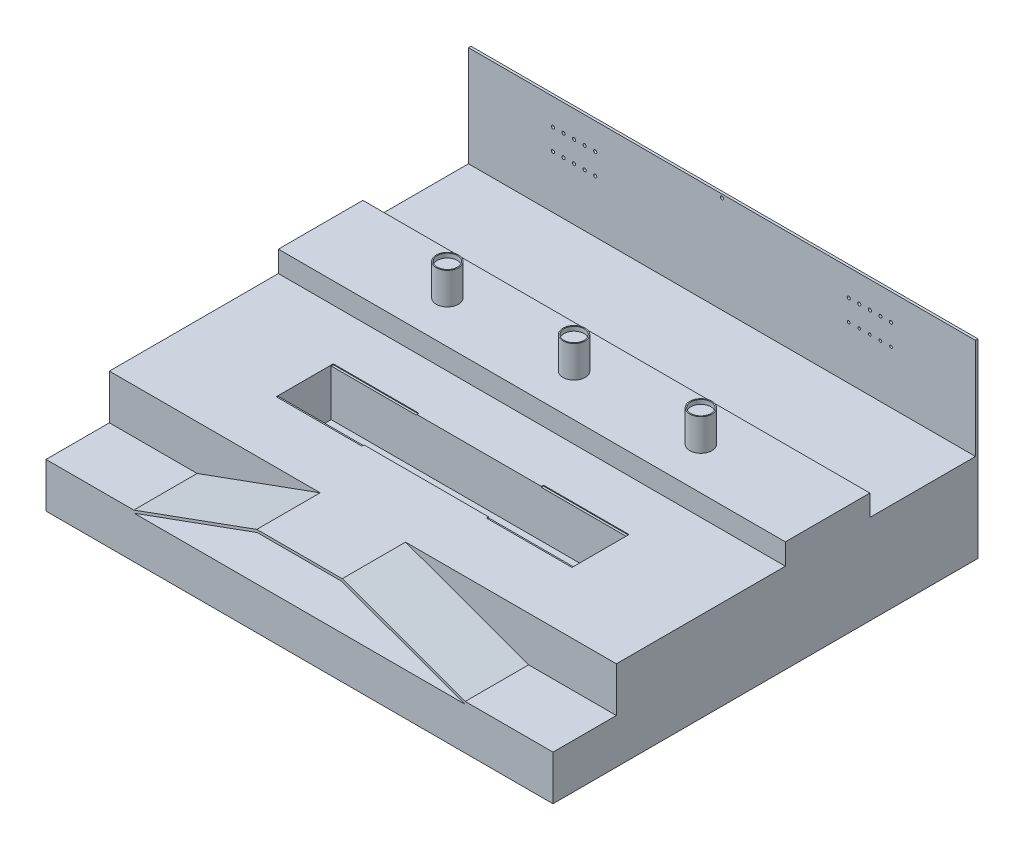
from build123d import *

# Parameters (mm, degrees)
EXTRUDE_1_DEPTH     = 300
SKETCH_2_W          = 2400
SKETCH_2_H          = 224
EXTRUDE_2_DEPTH     = 800
SKETCH_4_W          = 1400
SKETCH_4_H          = 250
CUT_EXTRUDE_1_DEPTH = 225
SKETCH_7_W          = 2400
SKETCH_7_H          = 324
EXTRUDE_3_DEPTH     = 400
SKETCH_9_W          = 2400
SKETCH_9_H          = 224
EXTRUDE_5_DEPTH     = 500
SKETCH_10_W         = 2400
SKETCH_10_H         = 700
EXTRUDE_6_DEPTH     = 12
SKETCH_12_W         = 2400
SKETCH_12_H         = 2012
EXTRUDE_8_DEPTH     = 200
SKETCH_13_R         = 52.5
EXTRUDE_9_DEPTH     = 150
SKETCH_14_R         = 7.5
SKETCH_14_R_2       = 6.5
CUT_EXTRUDE_2_DEPTH = 13
SKETCH_16_R         = 47.5
CUT_EXTRUDE_3_DEPTH = 20
SKETCH_17_W         = 405
SKETCH_17_H         = 10
CUT_EXTRUDE_4_DEPTH = 4


with BuildPart() as part:
    # 草图1 → 凸台-拉伸1 (new body)
    with BuildSketch(Plane.XY):
        Polygon((-200, 0), (200, 0), (782.465212924, -212), (1200, -212), (1200, -200), (784.581136693, -200), (202.115923769, 12), (-202.115923769, 12), (-784.581136693, -200), (-1200, -200), (-1200, -212), (-782.465212924, -212), align=None)
    extrude(amount=EXTRUDE_1_DEPTH)

    # 草图2 → 凸台-拉伸2 (add)
    with BuildSketch(Plane(origin=(0, 0, 0), x_dir=(-1, 0, 0), z_dir=(0, 0, -1))):
        with Locations((0, -100)):
            Rectangle(SKETCH_2_W, SKETCH_2_H)
    extrude(amount=EXTRUDE_2_DEPTH)

    # 草图4 → 切除-拉伸1 (cut, through all)
    with BuildSketch(Plane(origin=(0, 12, 0), x_dir=(1, 0, 0), z_dir=(0, 1, 0))):
        with Locations((0, 425)):
            Rectangle(SKETCH_4_W, SKETCH_4_H)
    extrude(amount=-CUT_EXTRUDE_1_DEPTH, mode=Mode.SUBTRACT)

    # 草图7 → 凸台-拉伸3 (add)
    with BuildSketch(Plane(origin=(0, 0, -800), x_dir=(-1, 0, 0), z_dir=(0, 0, -1))):
        with Locations((0, -50)):
            Rectangle(SKETCH_7_W, SKETCH_7_H)
    extrude(amount=EXTRUDE_3_DEPTH)

    # 草图9 → 凸台-拉伸5 (add)
    with BuildSketch(Plane(origin=(0, 0, -1200), x_dir=(-1, 0, 0), z_dir=(0, 0, -1))):
        with Locations((0, -100)):
            Rectangle(SKETCH_9_W, SKETCH_9_H)
    extrude(amount=EXTRUDE_5_DEPTH)

    # 草图10 → 凸台-拉伸6 (add)
    with BuildSketch(Plane(origin=(0, 0, -1700), x_dir=(-1, 0, 0), z_dir=(0, 0, -1))):
        with Locations((0, 138)):
            Rectangle(SKETCH_10_W, SKETCH_10_H)
    extrude(amount=EXTRUDE_6_DEPTH)

    # 草图12 → 凸台-拉伸8 (add)
    with BuildSketch(Plane.XZ.offset(212)):
        with Locations((0, -706)):
            Rectangle(SKETCH_12_W, SKETCH_12_H)
    extrude(amount=EXTRUDE_8_DEPTH)

    # 草图13 → 凸台-拉伸9 (add)
    with BuildSketch(Plane(origin=(0, 112, 0), x_dir=(1, 0, 0), z_dir=(0, 1, 0))):
        with Locations((-600, 1000)):
            Circle(SKETCH_13_R)
        with Locations((600, 1000)):
            Circle(SKETCH_13_R)
        with Locations((0, 1000)):
            Circle(SKETCH_13_R)
    extrude(amount=EXTRUDE_9_DEPTH)

    # 草图14 → 切除-拉伸2 (cut, through all)
    with BuildSketch(Plane.XY.offset(-1700)):
        with Locations((-800, 262)):
            Circle(SKETCH_14_R)
        with Locations((800, 362)):
            Circle(SKETCH_14_R)
        with Locations((-750, 262)):
            Circle(SKETCH_14_R)
        with Locations((-700, 262)):
            Circle(SKETCH_14_R)
        with Locations((-650, 262)):
            Circle(SKETCH_14_R)
        with Locations((-600, 262)):
            Circle(SKETCH_14_R)
        with Locations((750, 362)):
            Circle(SKETCH_14_R)
        with Locations((700, 362)):
            Circle(SKETCH_14_R)
        with Locations((650, 362)):
            Circle(SKETCH_14_R)
        with Locations((600, 362)):
            Circle(SKETCH_14_R)
        with Locations((0, 472)):
            Circle(SKETCH_14_R)
        with Locations((-800, 362)):
            Circle(SKETCH_14_R)
        with Locations((-750, 362)):
            Circle(SKETCH_14_R)
        with Locations((-700, 362)):
            Circle(SKETCH_14_R)
        with Locations((-650, 362)):
            Circle(SKETCH_14_R)
        with Locations((-600, 362)):
            Circle(SKETCH_14_R)
        with Locations((800, 262)):
            Circle(SKETCH_14_R_2)
        with Locations((750, 262)):
            Circle(SKETCH_14_R_2)
        with Locations((700, 262)):
            Circle(SKETCH_14_R_2)
        with Locations((650, 262)):
            Circle(SKETCH_14_R_2)
        with Locations((600, 262)):
            Circle(SKETCH_14_R_2)
    extrude(amount=-CUT_EXTRUDE_2_DEPTH, mode=Mode.SUBTRACT)

    # 草图16 → 切除-拉伸3 (cut)
    with BuildSketch(Plane(origin=(0, 262, 0), x_dir=(1, 0, 0), z_dir=(0, 1, 0))):
        with Locations((-600, 1000)):
            Circle(SKETCH_16_R)
        with Locations((0, 1000)):
            Circle(SKETCH_16_R)
        with Locations((600, 1000)):
            Circle(SKETCH_16_R)
    extrude(amount=-CUT_EXTRUDE_3_DEPTH, mode=Mode.SUBTRACT)

    # 草图17 → 切除-拉伸4 (cut)
    with BuildSketch(Plane(origin=(0, 12, 0), x_dir=(1, 0, 0), z_dir=(0, 1, 0))):
        with Locations((-497.5, 555)):
            Rectangle(SKETCH_17_W, SKETCH_17_H)
        with Locations((-497.5, 295)):
            Rectangle(SKETCH_17_W, SKETCH_17_H)
        with Locations((497.5, 555)):
            Rectangle(SKETCH_17_W, SKETCH_17_H)
        with Locations((497.5, 295)):
            Rectangle(SKETCH_17_W, SKETCH_17_H)
    extrude(amount=-CUT_EXTRUDE_4_DEPTH, mode=Mode.SUBTRACT)


solid = part.part
